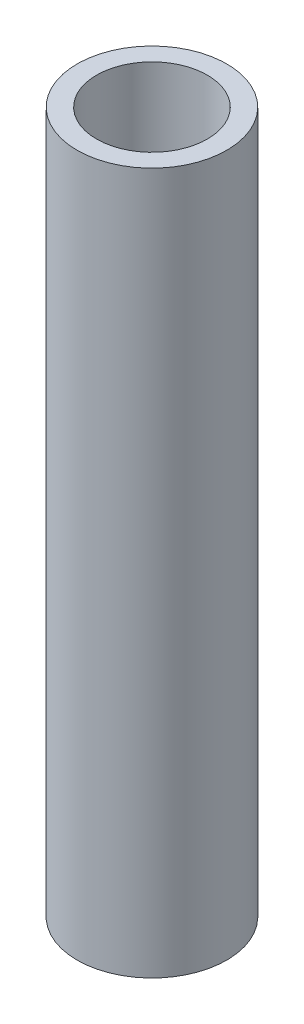
from build123d import *

# Parameters (mm, degrees)
SKETCH1_R           = 10.668
SKETCH1_R_2         = 7.8994
BOSS_EXTRUDE1_DEPTH = 100


with BuildPart() as part:
    # Sketch1 → Boss-Extrude1 (new body)
    with BuildSketch(Plane(origin=(0, 0, 0), x_dir=(1, 0, 0), z_dir=(0, 1, 0))):
        Circle(SKETCH1_R)
        Circle(SKETCH1_R_2, mode=Mode.SUBTRACT)
    extrude(amount=BOSS_EXTRUDE1_DEPTH)


solid = part.part
